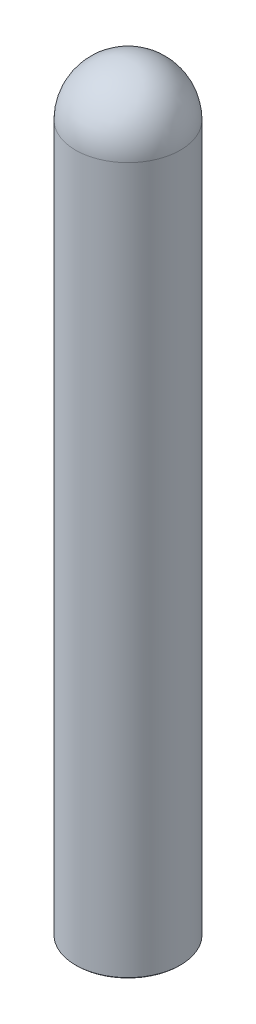
from build123d import *

# Parameters (mm, degrees)
THICKEN1_T2   = 1
CHAMFER1_SIZE = 0.04


with BuildPart() as body_1:
    # Surface-Revolve1: a surface, the sketch's curves turned about an axis
    with BuildLine(Plane.XY, mode=Mode.PRIVATE) as surface_revolve1_1_path:
        Line((2, 0), (2, 27))
        ThreePointArc((2, 27), (1.414213562, 28.414213562), (0, 29))
    surface_revolve1_1 = Shell.revolve(surface_revolve1_1_path.wire(), 360, Axis((0, 0, 0), (0, 1, 0)))
    add(Solid.thicken(surface_revolve1_1, -THICKEN1_T2))

    # Sketch2 → Revolve1 (revolve)
    with BuildSketch(Plane.XY, mode=Mode.PRIVATE) as revolve1_sk:
        with BuildLine():
            Line((0, 29), (0, 27))
            Line((0, 27), (-2, 27))
            ThreePointArc((-2, 27), (-1.414213562, 28.414213562), (0, 29))
        make_face()
    revolve(revolve1_sk.sketch.rotate(Axis((0, 29, 0), (0, -1, 0)), 270), axis=Axis((0, 29, 0), (0, -1, 0)))

    # Chamfer1
    chamfer1_edges = [body_1.edges().sort_by_distance(p)[0] for p in [
        (-2, 0, 0),
    ]]
    chamfer(chamfer1_edges, length=CHAMFER1_SIZE)


solid = body_1.part
